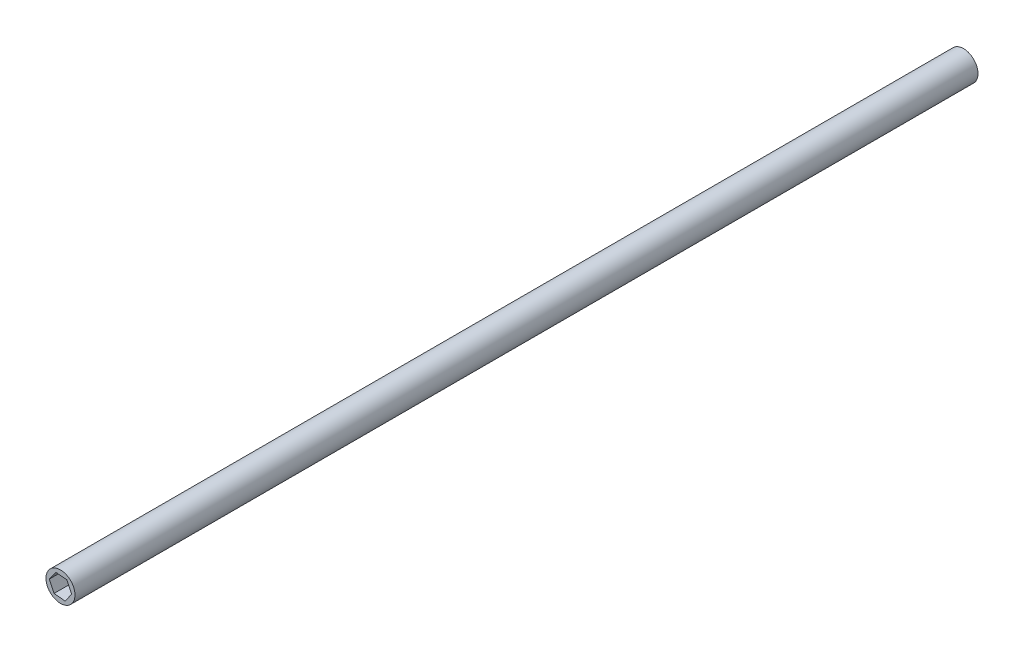
from build123d import *

# Parameters (mm, degrees)
SKETCH1_R           = 10
BOSS_EXTRUDE1_DEPTH = 600
SKETCH2_R           = 10
BOSS_EXTRUDE2_DEPTH = 22.5


with BuildPart() as part:
    # Sketch1 → Boss-Extrude1 (new body)
    with BuildSketch(Plane.XY):
        Circle(SKETCH1_R)
        Polygon((7.665529004, -0.706345771), (4.444477884, 6.285369965), (-3.22105112, 6.991715737), (-7.665529004, 0.706345771), (-4.444477884, -6.285369965), (3.22105112, -6.991715737), align=None, mode=Mode.SUBTRACT)
    extrude(amount=BOSS_EXTRUDE1_DEPTH)

    # Sketch2 → Boss-Extrude2 (add)
    with BuildSketch(Plane.XY):
        Circle(SKETCH2_R)
    extrude(amount=-BOSS_EXTRUDE2_DEPTH)


solid = part.part
